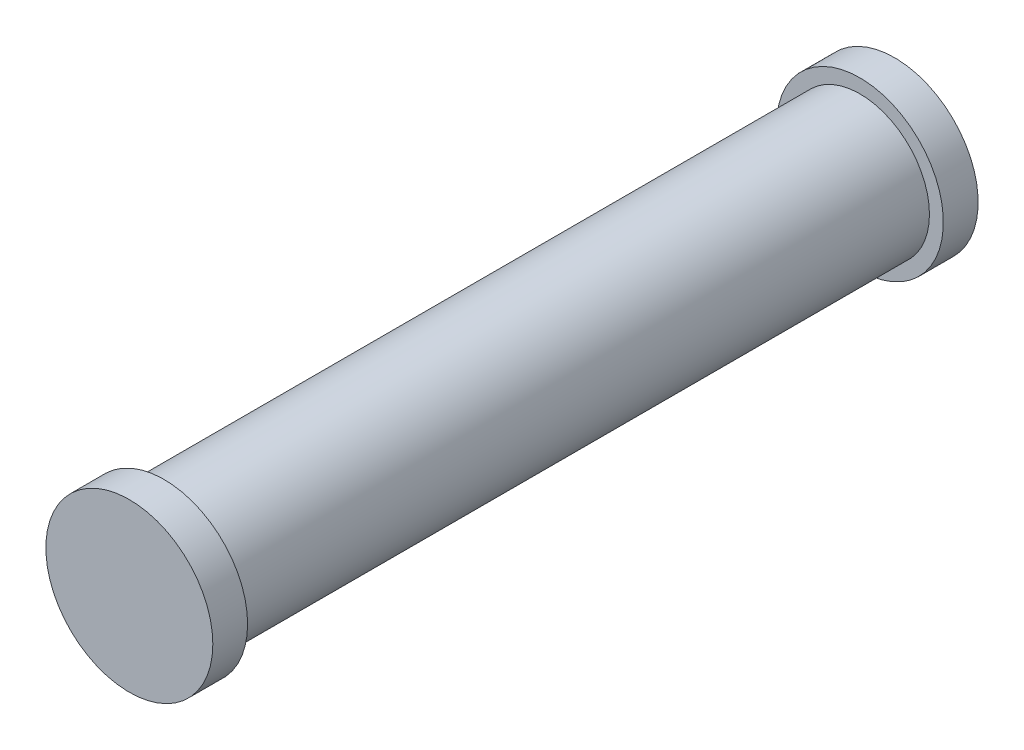
from build123d import *

# Parameters (mm, degrees)
CROQUIS1_R              = 0.5
SALIENTE_EXTRUIR1_DEPTH = 5
CROQUIS2_R              = 0.6
SALIENTE_EXTRUIR2_DEPTH = 0.25
SALIENTE_EXTRUIR3_START = 0.25
CROQUIS3_R              = 0.6
SALIENTE_EXTRUIR3_DEPTH = 0.25


with BuildPart() as part:
    # Croquis1 → Saliente-Extruir1 (new body)
    with BuildSketch(Plane.XY):
        Circle(CROQUIS1_R)
    extrude(amount=SALIENTE_EXTRUIR1_DEPTH)

    # Croquis2 → Saliente-Extruir2 (add)
    with BuildSketch(Plane.XY.offset(5)):
        Circle(CROQUIS2_R)
    extrude(amount=SALIENTE_EXTRUIR2_DEPTH)

    # Croquis3 → Saliente-Extruir3 (add)
    with BuildSketch(Plane(origin=(0, 0, 0), x_dir=(-1, 0, 0), z_dir=(0, 0, -1)).offset(SALIENTE_EXTRUIR3_START)):
        Circle(CROQUIS3_R)
    extrude(amount=-SALIENTE_EXTRUIR3_DEPTH)


solid = part.part
